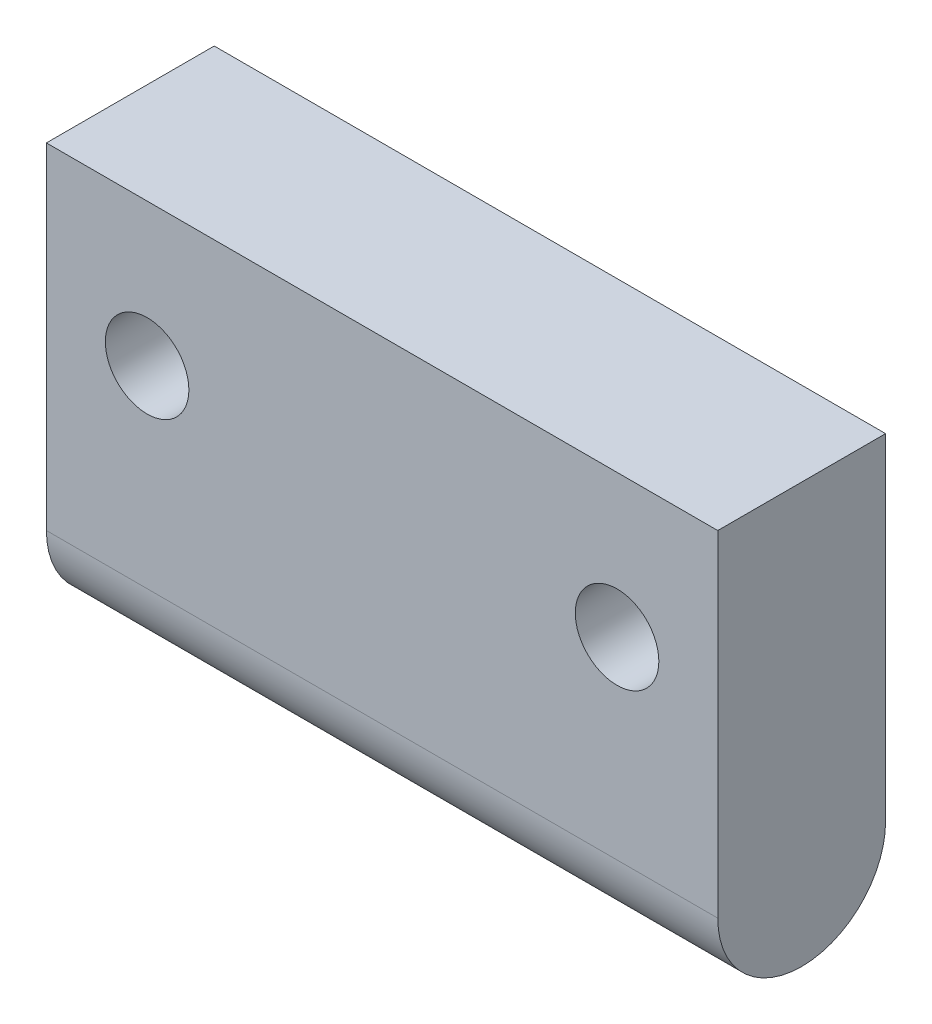
from build123d import *

# Parameters (mm, degrees)
BOSS_EXTRUDE1_DEPTH        = 20
F_10_CLEARANCE_HOLE1_D     = 4.9784
F_10_CLEARANCE_HOLE1_DEPTH = 29.83
F_10_CLEARANCE_HOLE1_TIP   = 1.495662253


with BuildPart() as part:
    # Sketch2 → Boss-Extrude1 (new body, symmetric)
    with BuildSketch(Plane(origin=(0, 0, 0), x_dir=(0, 0, -1), z_dir=(1, 0, 0))):
        with BuildLine():
            Line((0, 20), (0, 0))
            ThreePointArc((0, 0), (5, -5), (10, 0))
            Line((10, 0), (10, 20))
            Line((10, 20), (0, 20))
        make_face()
    extrude(amount=BOSS_EXTRUDE1_DEPTH, both=True)

    # #10 Clearance Hole1
    with Locations(Plane.XY):
        with Locations((-14, 11.5), (14, 11.5)):
            Hole(F_10_CLEARANCE_HOLE1_D / 2, depth=F_10_CLEARANCE_HOLE1_DEPTH)
            with Locations((0, 0, -(F_10_CLEARANCE_HOLE1_DEPTH + F_10_CLEARANCE_HOLE1_TIP / 2))):  # 118° drill point
                Cone(0, F_10_CLEARANCE_HOLE1_D / 2, F_10_CLEARANCE_HOLE1_TIP, mode=Mode.SUBTRACT)


solid = part.part
